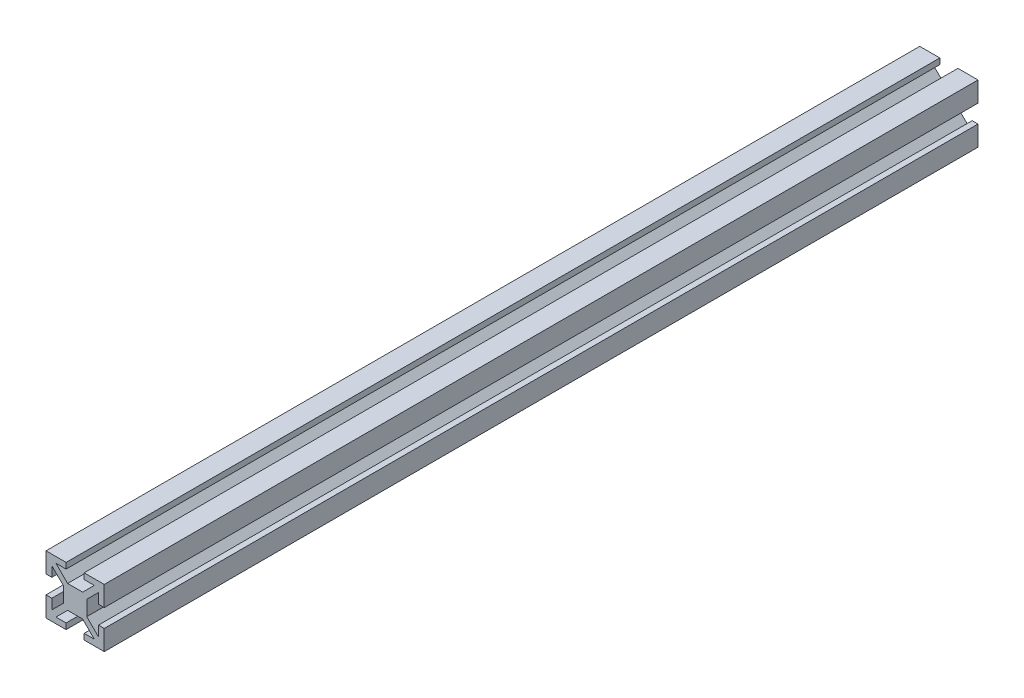
from build123d import *

# Parameters (mm, degrees)
BOSS_EXTRUDE1_DEPTH = 300
SKETCH2_R           = 2.6
CUT_EXTRUDE1_DEPTH  = 15


with BuildPart() as part:
    # Sketch1 → Boss-Extrude1 (new body)
    with BuildSketch(Plane.XY):
        Polygon((-8, 6.585786438), (-4, 2.585786438), (-4, -2.585786438), (-8, -6.585786438), (-8, -3.1), (-10, -3.1), (-10, -10), (-3.1, -10), (-3.1, -8), (-6.585786438, -8), (-2.585786438, -4), (2.585786438, -4), (6.585786438, -8), (3.1, -8), (3.1, -10), (10, -10), (10, -3.1), (8, -3.1), (8, -6.585786438), (4, -2.585786438), (4, 2.585786438), (8, 6.585786438), (8, 3.1), (10, 3.1), (10, 10), (3.1, 10), (3.1, 8), (6.585786438, 8), (2.585786438, 4), (-2.585786438, 4), (-6.585786438, 8), (-3.1, 8), (-3.1, 10), (-10, 10), (-10, 3.1), (-8, 3.1), align=None)
    extrude(amount=BOSS_EXTRUDE1_DEPTH)

    # Sketch2 → Cut-Extrude1 (cut, through all)
    with BuildSketch(Plane.ZY.offset(4)):
        with Locations((150, 0)):
            Circle(SKETCH2_R)
    extrude(amount=-CUT_EXTRUDE1_DEPTH, mode=Mode.SUBTRACT)


solid = part.part
